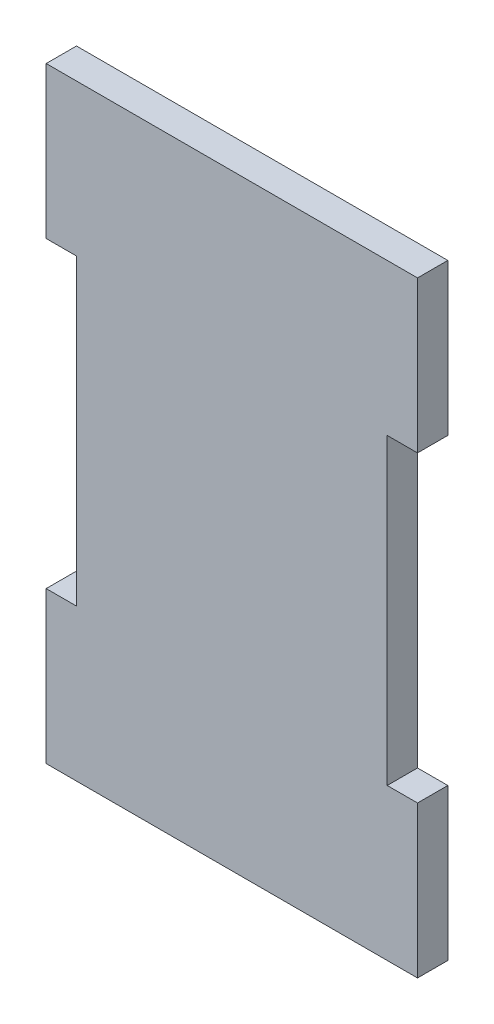
from build123d import *

# Parameters (mm, degrees)
SKETCH2_W           = 52.07
SKETCH2_H           = 101.6
SKETCH2_W_2         = 5.08
SKETCH2_H_2         = 25.4
BOSS_EXTRUDE1_DEPTH = 5.08


with BuildPart() as part:
    # Sketch2 → Boss-Extrude1 (new body)
    with BuildSketch(Plane.XY):
        Rectangle(SKETCH2_W, SKETCH2_H)
        with Locations((-28.575, 38.1)):
            Rectangle(SKETCH2_W_2, SKETCH2_H_2)
        with Locations((-28.575, -38.1)):
            Rectangle(SKETCH2_W_2, SKETCH2_H_2)
        with Locations((28.575, -38.1)):
            Rectangle(SKETCH2_W_2, SKETCH2_H_2)
        with Locations((28.575, 38.1)):
            Rectangle(SKETCH2_W_2, SKETCH2_H_2)
    extrude(amount=BOSS_EXTRUDE1_DEPTH)


solid = part.part
